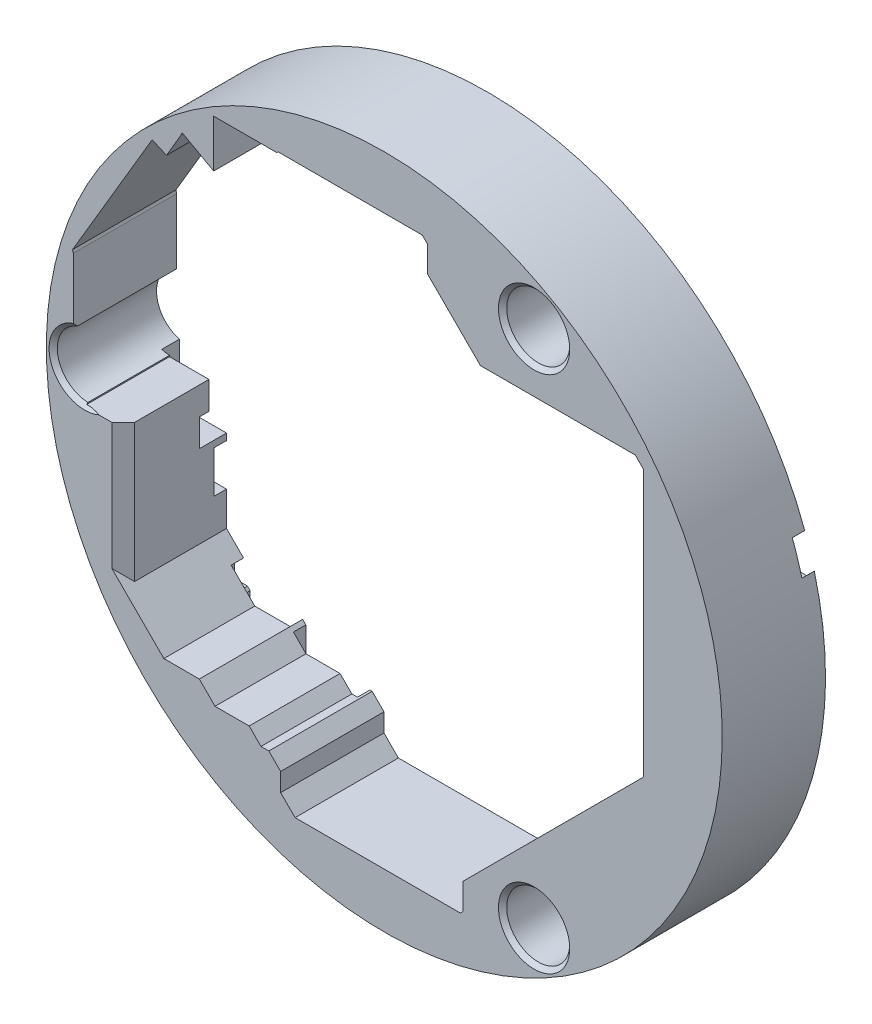
from build123d import *

# Parameters (mm, degrees)
SKETCH_2_R           = 32.71124014
SKETCH_2_R_2         = 3.04999898
EXTRUDE_1_DEPTH      = 10
CUT_EXTRUDE_1_DEPTH  = 10
SKETCH_3_W           = 4.826
SKETCH_3_H           = 3.683
CUT_EXTRUDE_2_DEPTH  = 10
SKETCH_4_R           = 3.09999888
CUT_EXTRUDE_3_DEPTH  = 1.2
SKETCH_5_W           = 6.131993656
SKETCH_5_H           = 3.833791951
SKETCH_5_W_2         = 6.200437112
SKETCH_5_H_2         = 5.346426118
CUT_EXTRUDE_7_DEPTH  = 1.2
SKETCH_6_W           = 4.064
SKETCH_6_H           = 4.064
SKETCH_6_W_2         = 7.366
SKETCH_6_H_2         = 3.683
CUT_EXTRUDE_8_DEPTH  = 1.2
SKETCH_7_W           = 4.826
SKETCH_7_H           = 3.556
CUT_EXTRUDE_9_DEPTH  = 2.6
CHAMFER_1_SIZE       = 0.4
CUT_EXTRUDE_10_DEPTH = 1.7
SKETCH_9_W           = 5.344198096
SKETCH_9_H           = 4.530795449
CUT_EXTRUDE_11_DEPTH = 10
CHAMFER_3_SIZE       = 2
SKETCH_10_W          = 6.099936029
SKETCH_10_H          = 6.019169357
CUT_EXTRUDE_12_DEPTH = 10
CHAMFER_5_SIZE       = 1.1
CHAMFER_6_SIZE       = 2


with BuildPart() as part:
    # 草图2 → 凸台-拉伸1 (new body)
    with BuildSketch(Plane.XY):
        with Locations((99.695, 76.454)):
            Circle(SKETCH_2_R)
        with Locations((114.19499894, 101.56873768)):
            Circle(SKETCH_2_R_2, mode=Mode.SUBTRACT)
        with Locations((114.19511324, 51.33906674)):
            Circle(SKETCH_2_R_2, mode=Mode.SUBTRACT)
        with Locations((70.69477352, 76.454)):
            Circle(SKETCH_2_R_2, mode=Mode.SUBTRACT)
    extrude(amount=EXTRUDE_1_DEPTH)

    # 草图1 → 切除-拉伸1 (cut)
    with BuildSketch(Plane.XY):
        Polygon((72.39, 79.248), (74.422, 77.216), (74.422, 59.944), (78.359, 56.007), (81.788, 56.007), (83.312, 54.483), (86.614, 54.483), (87.757, 53.34), (88.519, 53.34), (89.662, 52.197), (89.662, 50.419), (91.059, 49.022), (107.061, 49.022), (107.315, 49.276), (107.315, 51.816), (122.809, 67.31), (122.809, 94.234), (121.158, 95.885), (106.172, 95.885), (103.886, 98.171), (103.886, 103.505), (103.378, 104.013), (89.408, 104.013), (89.281, 103.886), (89.281, 99.568), (88.265, 98.552), (84.61794354, 98.48969888), (82.677, 99.568), (80.137, 100.965), (80.01, 100.711), (78.61743992, 98.3237556), (77.22353618, 98.92855246), (69.52377256, 85.87810358), (69.596, 85.598), (69.596, 80.899), (70.866, 79.629), (71.501, 79.629), (71.882, 79.248), align=None)
    extrude(amount=CUT_EXTRUDE_1_DEPTH, mode=Mode.SUBTRACT)

    # 草图3 → 切除-拉伸2 (cut)
    with BuildSketch(Plane.XY):
        with Locations((72.009, 79.0575)):
            Rectangle(SKETCH_3_W, SKETCH_3_H)
    extrude(amount=CUT_EXTRUDE_2_DEPTH, mode=Mode.SUBTRACT)

    # 草图4 → 切除-拉伸3 (cut)
    with BuildSketch(Plane.XY):
        with Locations((128.69500042, 76.454)):
            Circle(SKETCH_4_R)
        with Locations((85.19500106, 51.3390007)):
            Circle(SKETCH_4_R)
        with Locations((85.19500106, 101.5689993)):
            Circle(SKETCH_4_R)
    extrude(amount=CUT_EXTRUDE_3_DEPTH, mode=Mode.SUBTRACT)

    # 草图5 → 切除-拉伸7 (cut)
    with BuildSketch(Plane.XY):
        with Locations((85.199003172, 99.987807393)):
            Rectangle(SKETCH_5_W, SKETCH_5_H)
        with Locations((85.195209049, 54.011411306)):
            Rectangle(SKETCH_5_W_2, SKETCH_5_H_2)
    extrude(amount=CUT_EXTRUDE_7_DEPTH, mode=Mode.SUBTRACT)

    # 草图6 → 切除-拉伸8 (cut)
    with BuildSketch(Plane.XY):
        Polygon((76.327, 58.293), (75.692, 58.293), (75.184, 58.293), (75.184, 56.388), (75.438, 56.134), (76.454, 56.134), (76.708, 55.88), (76.708, 54.483), (76.962, 54.229), (77.724, 54.229), (77.851, 54.102), (77.851, 53.594), (78.105, 53.34), (81.788, 53.34), (81.788, 58.293), align=None)
        with Locations((72.771, 65.278)):
            Rectangle(SKETCH_6_W, SKETCH_6_H)
        with Locations((127.635, 85.9155)):
            Rectangle(SKETCH_6_W_2, SKETCH_6_H_2)
        Polygon((94.742, 104.394), (94.742, 107.188), (103.886, 107.188), (103.886, 100.457), (94.742, 100.457), align=None)
    extrude(amount=CUT_EXTRUDE_8_DEPTH, mode=Mode.SUBTRACT)

    # 草图7 → 切除-拉伸9 (cut)
    with BuildSketch(Plane.XY):
        with Locations((91.694, 104.775)):
            Rectangle(SKETCH_7_W, SKETCH_7_H)
        Polygon((74.549, 67.945), (75.057, 67.945), (75.057, 70.612), (69.723, 70.612), (69.723, 67.945), align=None)
    extrude(amount=CUT_EXTRUDE_9_DEPTH, mode=Mode.SUBTRACT)

    # 倒角1
    chamfer_1_edges = [part.edges().sort_by_distance(p)[0] for p in [
        (69.300236993, 73.741480571, 10),
        (111.14499996, 101.56873768, 10),
        (111.14511426, 51.33906674, 10),
    ]]
    chamfer(chamfer_1_edges, length=CHAMFER_1_SIZE)

    # 草图8 → 切除-拉伸10 (cut)
    with BuildSketch(Plane.XY):
        Polygon((69.85, 68.072), (69.85, 72.39), (69.85, 73.536945765), (69.98685425, 73.673800015), (72.530800015, 73.673800015), (72.644, 73.787), (72.644, 78.994), (72.898, 79.248), (74.93, 79.248), (75.438, 78.74), (75.438, 72.898), (74.422, 71.882), (74.422, 68.072), align=None)
    extrude(amount=CUT_EXTRUDE_10_DEPTH, mode=Mode.SUBTRACT)

    # 草图9 → 切除-拉伸11 (cut)
    with BuildSketch(Plane.XY):
        with Locations((73.278206637, 75.553819753)):
            Rectangle(SKETCH_9_W, SKETCH_9_H)
    extrude(amount=CUT_EXTRUDE_11_DEPTH, mode=Mode.SUBTRACT)

    # 倒角3
    chamfer_3_edges = [part.edges().sort_by_distance(p)[0] for p in [
        (122.809, 80.772, 10),
        (121.9835, 95.0595, 10),
    ]]
    chamfer(chamfer_3_edges, length=CHAMFER_3_SIZE)

    # 草图10 → 切除-拉伸12 (cut)
    with BuildSketch(Plane.XY):
        with Locations((86.231031986, 100.876415322)):
            Rectangle(SKETCH_10_W, SKETCH_10_H)
    extrude(amount=CUT_EXTRUDE_12_DEPTH, mode=Mode.SUBTRACT)

    # 倒角5
    chamfer_5_edges = [part.edges().sort_by_distance(p)[0] for p in [
        (74.422, 66.616211014, 10),
    ]]
    chamfer(chamfer_5_edges, length=CHAMFER_5_SIZE)

    # 倒角6
    chamfer_6_edges = [part.edges().sort_by_distance(p)[0] for p in [
        (105.029, 97.028, 10),
    ]]
    chamfer(chamfer_6_edges, length=CHAMFER_6_SIZE)


solid = part.part
